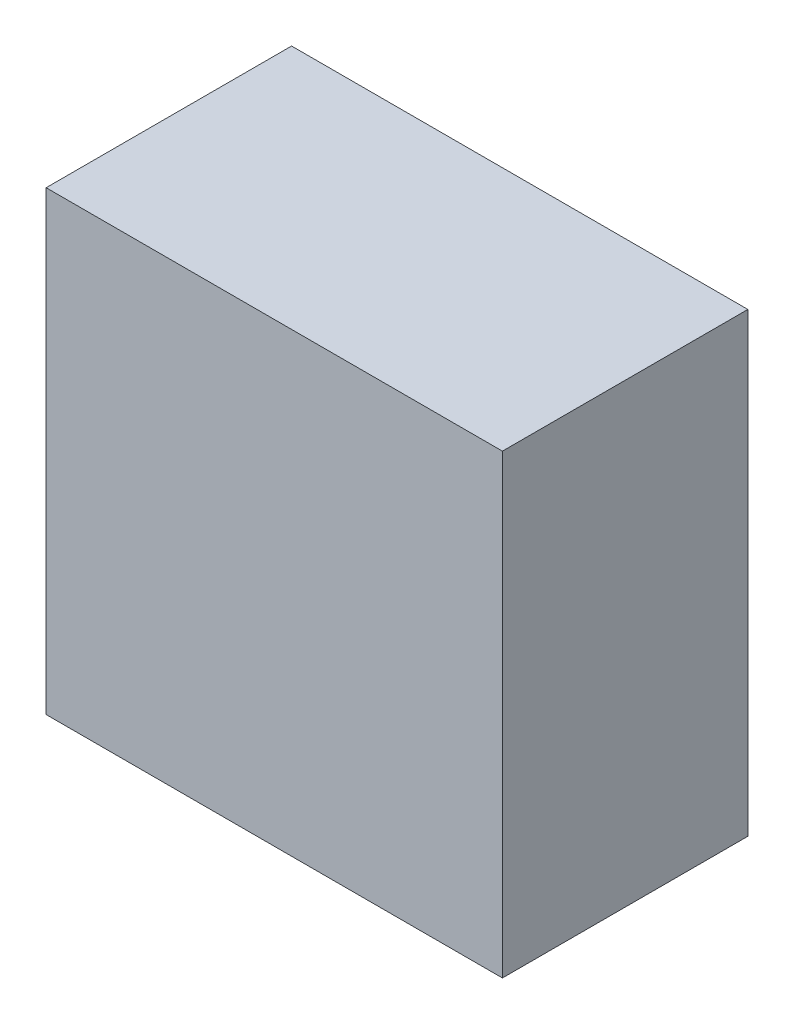
from build123d import *

# Parameters (mm, degrees)
SKETCH1_W           = 145
SKETCH1_H           = 145
BOSS_EXTRUDE1_DEPTH = 78


with BuildPart() as part:
    # Sketch1 → Boss-Extrude1 (new body)
    with BuildSketch(Plane.XY):
        with Locations((527.5, 0)):
            Rectangle(SKETCH1_W, SKETCH1_H)
    extrude(amount=BOSS_EXTRUDE1_DEPTH)


solid = part.part
